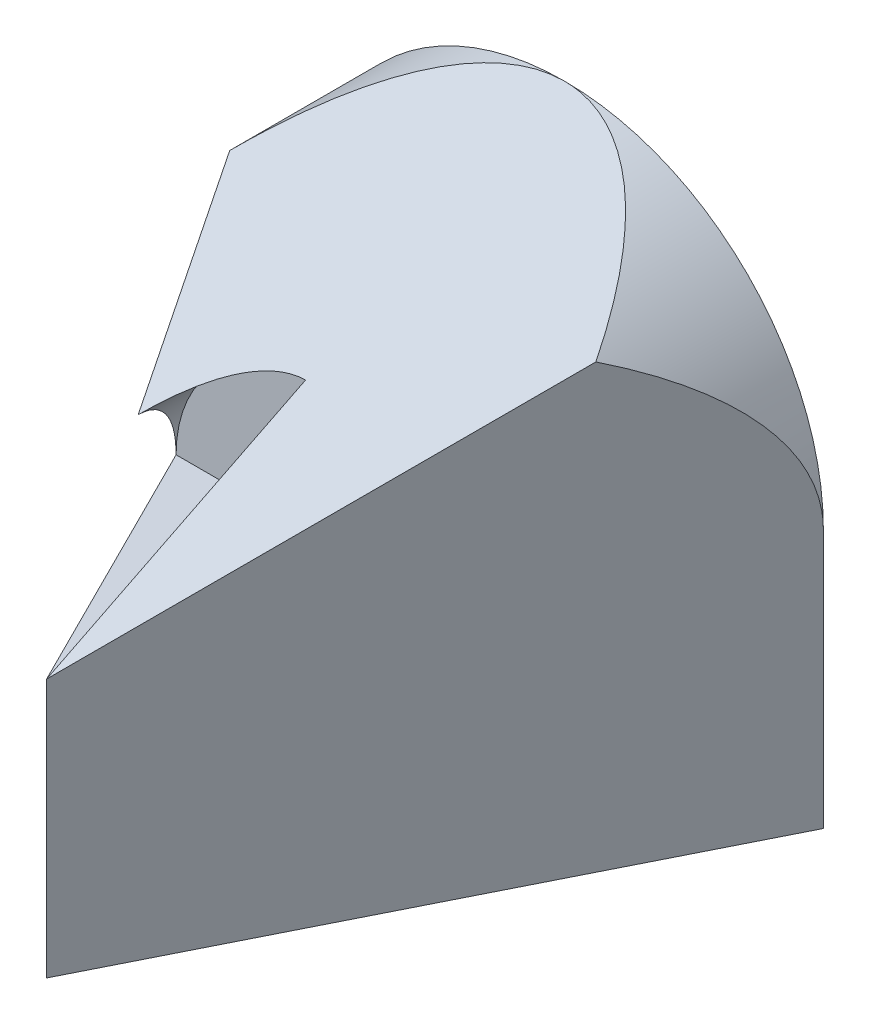
from build123d import *

# Parameters (mm, degrees)
SKETCH1_W           = 40
SKETCH1_H           = 20
BOSS_EXTRUDE1_DEPTH = 40
CUT_EXTRUDE18_DEPTH = 20
CUT_EXTRUDE20_DEPTH = 59
CUT_EXTRUDE21_DEPTH = 59


with BuildPart() as part:
    # Sketch1 → Boss-Extrude1 (new body)
    with BuildSketch(Plane.XY):
        with BuildLine():
            Line((0, 20), (40, 20))
            ThreePointArc((40, 20), (20, 40), (0, 20))
        make_face()
        with Locations((20, 10)):
            Rectangle(SKETCH1_W, SKETCH1_H)
    extrude(amount=BOSS_EXTRUDE1_DEPTH)

    # Sketch4 → Cut-Extrude18 (cut)
    with BuildSketch(Plane.XY.offset(40)):
        with BuildLine():
            Line((20, 30), (20, 20))
            Line((20, 20), (10, 20))
            ThreePointArc((10, 20), (12.928932188, 27.071067812), (20, 30))
        make_face()
    extrude(amount=-CUT_EXTRUDE18_DEPTH, mode=Mode.SUBTRACT)

    # Sketch11 → Cut-Extrude20 (cut)
    with BuildSketch(Plane(origin=(0, 0, 0), x_dir=(1, 0, 0), z_dir=(0, 1, 0))):
        Polygon((20, -40), (0, 0), (0, -40), align=None)
        Polygon((40, 0), (20, -40), (40, -40), align=None)
    extrude(amount=CUT_EXTRUDE20_DEPTH, mode=Mode.SUBTRACT)

    # Sketch12 → Cut-Extrude21 (cut)
    with BuildSketch(Plane(origin=(0, 0, 0), x_dir=(0, 0, -1), z_dir=(1, 0, 0))):
        Polygon((-40, 20), (0, 40), (-40, 40), align=None)
    extrude(amount=CUT_EXTRUDE21_DEPTH, mode=Mode.SUBTRACT)


solid = part.part
